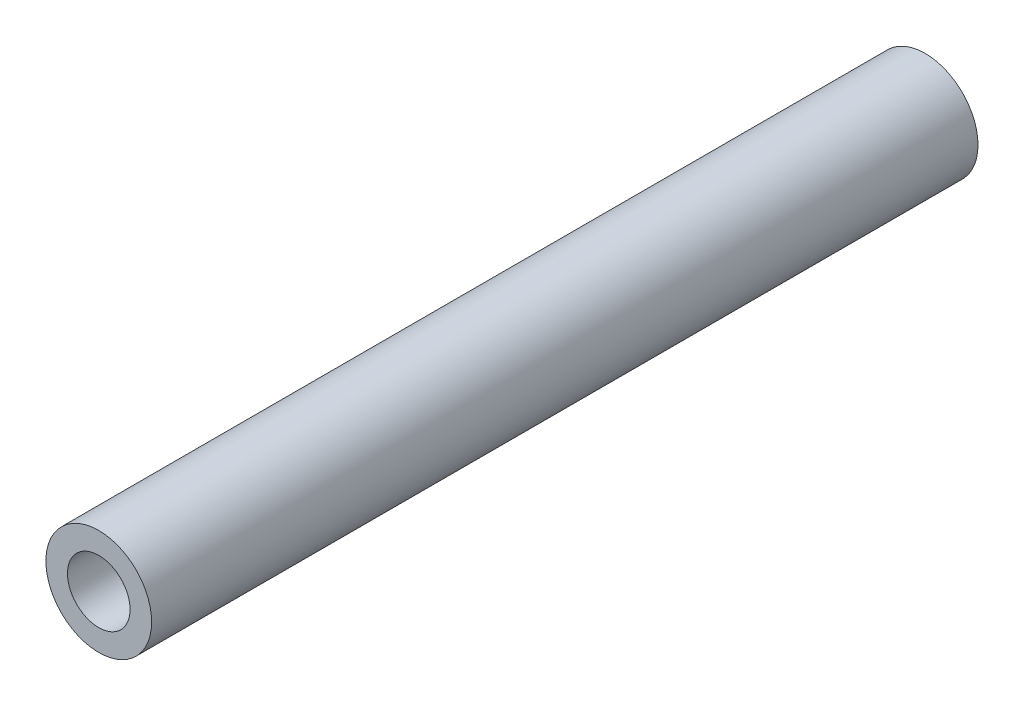
from build123d import *

# Parameters (mm, degrees)
ESQUISSE1_R        = 2.45
ESQUISSE1_R_2      = 1.45
BOSS_EXTRU_1_DEPTH = 38.3


with BuildPart() as part:
    # Esquisse1 → Boss.-Extru.1 (new body)
    with BuildSketch(Plane.XY):
        Circle(ESQUISSE1_R)
        Circle(ESQUISSE1_R_2, mode=Mode.SUBTRACT)
    extrude(amount=BOSS_EXTRU_1_DEPTH)


solid = part.part
